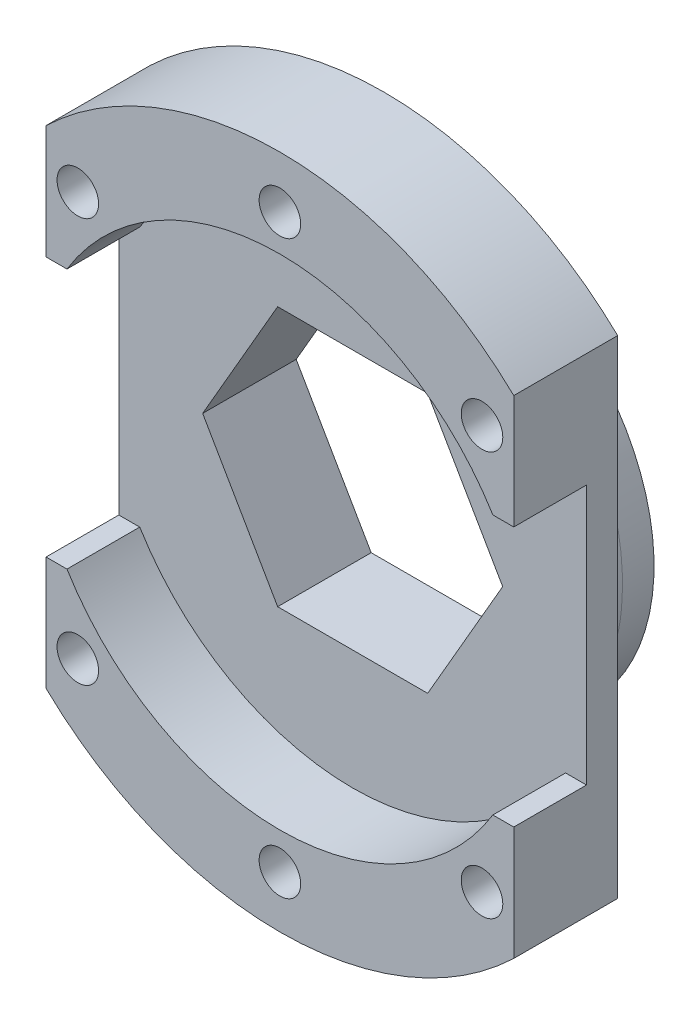
from build123d import *

# Parameters (mm, degrees)
SKETCH1_R           = 32.5
BOSS_EXTRUDE1_DEPTH = 10
CUT_EXTRUDE1_DEPTH  = 5
SKETCH3_R           = 2
CUT_EXTRUDE2_DEPTH  = 11
SKETCH4_R           = 20
BOSS_EXTRUDE2_DEPTH = 6
CUT_EXTRUDE3_DEPTH  = 17
SKETCH6_R           = 24
CUT_EXTRUDE5_DEPTH  = 7
CUT_EXTRUDE6_DEPTH  = 11
SKETCH8_W           = 45
SKETCH8_H           = 25
CUT_EXTRUDE7_DEPTH  = 8
FILLET1_R           = 3


with BuildPart() as part:
    # Sketch1 → Boss-Extrude1 (new body)
    with BuildSketch(Plane.XY):
        Circle(SKETCH1_R)
    extrude(amount=BOSS_EXTRUDE1_DEPTH)

    # Sketch2 → Cut-Extrude1 (cut)
    with BuildSketch(Plane.XY.offset(10)):
        Polygon((14.43375673, 0), (7.216878365, 12.5), (-7.216878365, 12.5), (-14.43375673, 0), (-7.216878365, -12.5), (7.216878365, -12.5), align=None)
    extrude(amount=-CUT_EXTRUDE1_DEPTH, mode=Mode.SUBTRACT)

    # Sketch3 → Cut-Extrude2 (cut, through all)
    with BuildSketch(Plane.XY.offset(10)):
        with Locations((0, 27.5)):
            Circle(SKETCH3_R)
        with Locations((19.445436483, 19.445436483)):
            Circle(SKETCH3_R)
        with Locations((27.5, 0)):
            Circle(SKETCH3_R)
        with Locations((19.445436483, -19.445436483)):
            Circle(SKETCH3_R)
        with Locations((0, -27.5)):
            Circle(SKETCH3_R)
        with Locations((-19.445436483, -19.445436483)):
            Circle(SKETCH3_R)
        with Locations((-27.5, 0)):
            Circle(SKETCH3_R)
        with Locations((-19.445436483, 19.445436483)):
            Circle(SKETCH3_R)
    extrude(amount=-CUT_EXTRUDE2_DEPTH, mode=Mode.SUBTRACT)

    # Sketch4 → Boss-Extrude2 (add)
    with BuildSketch(Plane(origin=(0, 0, 0), x_dir=(-1, 0, 0), z_dir=(0, 0, -1))):
        Circle(SKETCH4_R)
        Polygon((14.43375673, 0), (7.216878365, 12.5), (-7.216878365, 12.5), (-14.43375673, 0), (-7.216878365, -12.5), (7.216878365, -12.5), align=None, mode=Mode.SUBTRACT)
    extrude(amount=BOSS_EXTRUDE2_DEPTH)

    # Sketch5 → Cut-Extrude3 (cut, through all)
    with BuildSketch(Plane.XY.offset(10)):
        with BuildLine():
            Line((22.5, 23.452078799), (22.5, -23.452078799))
            ThreePointArc((22.5, -23.452078799), (32.5, 0), (22.5, 23.452078799))
        make_face()
        with BuildLine():
            Line((-22.5, 23.452078799), (-22.5, -23.452078799))
            ThreePointArc((-22.5, -23.452078799), (-32.5, 0), (-22.5, 23.452078799))
        make_face()
    extrude(amount=-CUT_EXTRUDE3_DEPTH, mode=Mode.SUBTRACT)

    # Sketch6 → Cut-Extrude5 (cut)
    with BuildSketch(Plane.XY.offset(10)):
        Circle(SKETCH6_R)
    extrude(amount=-CUT_EXTRUDE5_DEPTH, mode=Mode.SUBTRACT)

    # Sketch7 → Cut-Extrude6 (cut, through all)
    with BuildSketch(Plane(origin=(0, 0, 0), x_dir=(-1, 0, 0), z_dir=(0, 0, -1))):
        Polygon((14.43375673, 0), (7.216878365, 12.5), (-7.216878365, 12.5), (-14.43375673, 0), (-7.216878365, -12.5), (7.216878365, -12.5), align=None)
    extrude(amount=-CUT_EXTRUDE6_DEPTH, mode=Mode.SUBTRACT)

    # Sketch8 → Cut-Extrude7 (cut, through all)
    with BuildSketch(Plane.XY.offset(3)):
        Rectangle(SKETCH8_W, SKETCH8_H)
    extrude(amount=CUT_EXTRUDE7_DEPTH, mode=Mode.SUBTRACT)

    # Fillet1
    fillet1_edges = [part.edges().sort_by_distance(p)[0] for p in [
        (20, 0, 0),
    ]]
    fillet(fillet1_edges, radius=FILLET1_R)


solid = part.part
